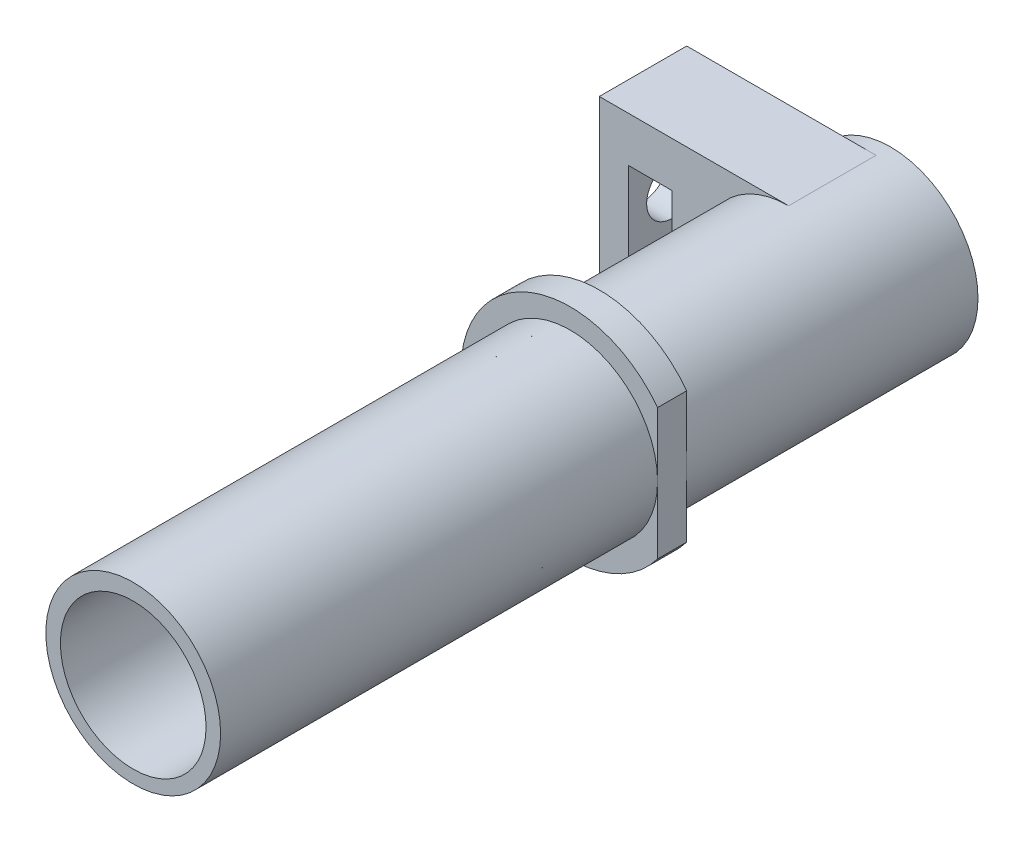
from build123d import *

# Parameters (mm, degrees)
ESQUISSE1_R             = 7.5
ESQUISSE1_R_2           = 5
BOSS_EXTRU_1_DEPTH      = 2
ESQUISSE2_R             = 6
ESQUISSE2_R_2           = 5
BOSS_EXTRU_2_DEPTH      = 30
ESQUISSE3_R             = 6
ESQUISSE3_R_2           = 5
BOSS_EXTRU_3_DEPTH      = 20
ENL_V_MAT_EXTRU_1_DEPTH = 33
BOSS_EXTRU_4_DEPTH      = 3
ESQUISSE8_R             = 1.75
ENL_V_MAT_EXTRU_3_DEPTH = 16
ESQUISSE9_W             = 3
ESQUISSE9_H             = 5.8
ENL_V_MAT_EXTRU_4_DEPTH = 6


with BuildPart() as part:
    # Esquisse1 → Boss.-Extru.1 (new body)
    with BuildSketch(Plane.XY):
        Circle(ESQUISSE1_R)
        Circle(ESQUISSE1_R_2, mode=Mode.SUBTRACT)
    extrude(amount=BOSS_EXTRU_1_DEPTH)

    # Esquisse2 → Boss.-Extru.2 (add)
    with BuildSketch(Plane.XY.offset(2)):
        with Locations((0, 0.114284202)):
            Circle(ESQUISSE2_R)
        Circle(ESQUISSE2_R_2, mode=Mode.SUBTRACT)
    extrude(amount=BOSS_EXTRU_2_DEPTH)

    # Esquisse3 → Boss.-Extru.3 (add)
    with BuildSketch(Plane(origin=(0, 0, 0), x_dir=(-1, 0, 0), z_dir=(0, 0, -1))):
        Circle(ESQUISSE3_R)
        Circle(ESQUISSE3_R_2, mode=Mode.SUBTRACT)
    extrude(amount=BOSS_EXTRU_3_DEPTH)

    # Esquisse4 → Enlèv. mat.-Extru.1 (cut, through all)
    with BuildSketch(Plane(origin=(0, 0, 0), x_dir=(-1, 0, 0), z_dir=(0, 0, -1))):
        with BuildLine():
            Line((-6, 4.5), (-6, -4.5))
            ThreePointArc((-6, -4.5), (-7.5, 0), (-6, 4.5))
        make_face()
    extrude(amount=-ENL_V_MAT_EXTRU_1_DEPTH, mode=Mode.SUBTRACT)

    # Esquisse7 → Boss.-Extru.4 (add, symmetric)
    with BuildSketch(Plane(origin=(0, 0, -16), x_dir=(-1, 0, 0), z_dir=(0, 0, -1))):
        with BuildLine():
            Line((0, 6), (13, 6))
            Line((13, 6), (13, -6))
            Line((13, -6), (0, -6))
            ThreePointArc((0, -6), (6, 0), (0, 6))
        make_face()
    extrude(amount=BOSS_EXTRU_4_DEPTH, both=True)

    # Esquisse8 → Enlèv. mat.-Extru.3 (cut)
    with BuildSketch(Plane.ZY.offset(13)):
        with Locations((-16, 0)):
            Circle(ESQUISSE8_R)
    extrude(amount=-ENL_V_MAT_EXTRU_3_DEPTH, mode=Mode.SUBTRACT)

    # Esquisse9 → Enlèv. mat.-Extru.4 (cut)
    with BuildSketch(Plane(origin=(0, 0, -19), x_dir=(-1, 0, 0), z_dir=(0, 0, -1))):
        with Locations((9.5, 0)):
            Rectangle(ESQUISSE9_W, ESQUISSE9_H)
    extrude(amount=-ENL_V_MAT_EXTRU_4_DEPTH, mode=Mode.SUBTRACT)


solid = part.part
